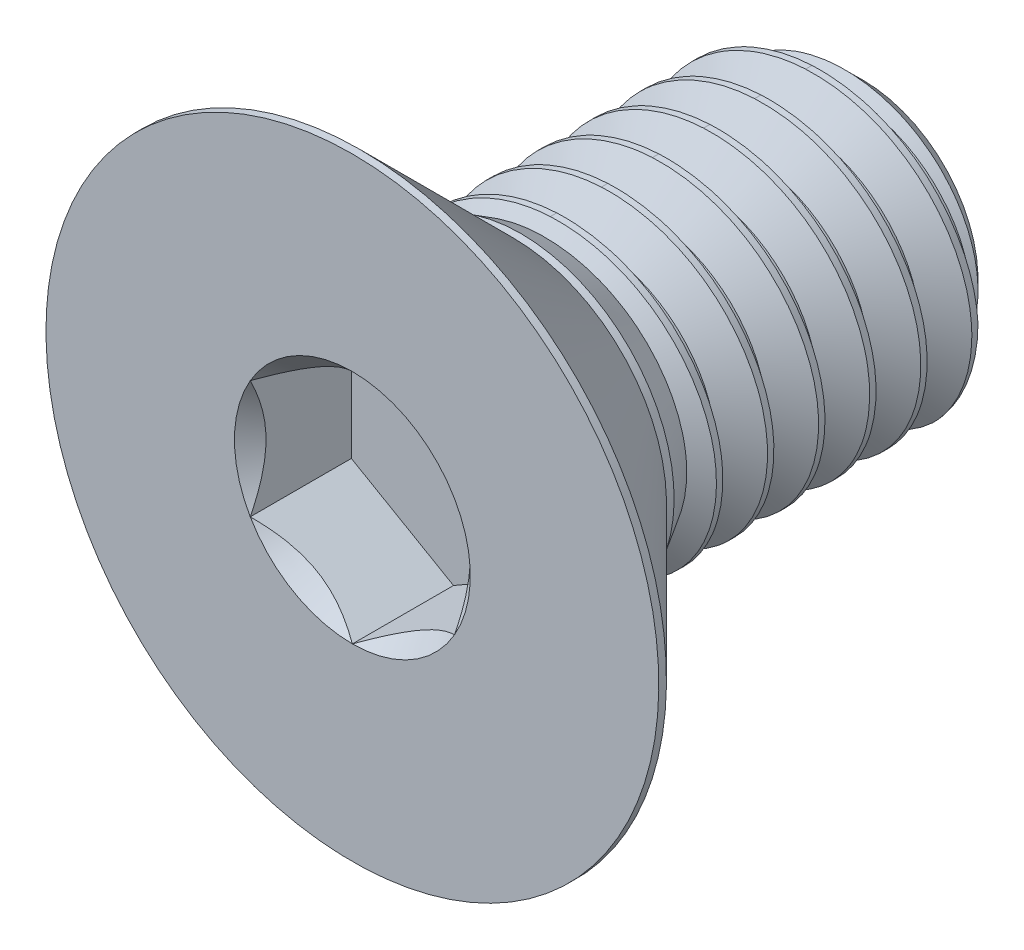
from build123d import *

# Parameters (mm, degrees)
CUT_EXTRUDE2_DEPTH     = 1.98
SKETCH6_R              = 2.309401077
CUT_EXTRUDE3_DEPTH     = 1.98
CUT_EXTRUDE3_DRAFT     = -45
CUT_SWEEP1_PITCH       = 1
CUT_SWEEP1_HEIGHT      = 7.7
CUT_SWEEP1_RADIUS      = 3
CUT_SWEEP1_START_ANGLE = 90


with BuildPart() as part:
    # Sketch7 → Revolve2 (revolve)
    with BuildSketch(Plane(origin=(0, 0, 0), x_dir=(0, 0, -1), z_dir=(1, 0, 0))):
        Polygon((-3.3, 0), (-3.3, 6), (-3.15, 6), (-0.15, 3), (5.95, 3), (6.7, 2.25), (6.7, 0), align=None)
    revolve(axis=Axis((0, 0, -6.7), (0, 0, 1)))

    # Sketch5 → Cut-Extrude2 (cut)
    with BuildSketch(Plane.XY.offset(3.3)):
        Polygon((2, -1.154700538), (2, 1.154700538), (0, 2.309401077), (-2, 1.154700538), (-2, -1.154700538), (0, -2.309401077), align=None)
    extrude(amount=-CUT_EXTRUDE2_DEPTH, mode=Mode.SUBTRACT)


with BuildPart() as cut_extrude3_tool:
    # Sketch6 → Cut-Extrude3 (with draft: the straight prism first)
    with BuildSketch(Plane.XY.offset(3.3)):
        Circle(SKETCH6_R)
    extrude(amount=-CUT_EXTRUDE3_DEPTH)
    # Cut-Extrude3: the draft: its side faces are tilted about the plane it starts from
    cut_extrude3_sides = [cut_extrude3_tool.faces().sort_by_distance(p)[0] for p in [
        (-2.309401077, 0, 2.31),
    ]]
    draft(cut_extrude3_sides, Plane.XY.offset(3.3), CUT_EXTRUDE3_DRAFT)


with BuildPart() as part_1:
    add(part.part)

    # Cut-Extrude3: cut by cut_extrude3_tool
    add(cut_extrude3_tool.part, mode=Mode.SUBTRACT)


with BuildPart() as body_2:
    # Split1: the piece on the far side of the plane
    add(part_1.part)
    split(bisect_by=Plane.XY, keep=Keep.BOTTOM)

    # Cut-Sweep1: sweep along a helix
    with BuildLine() as cut_sweep1_path:
        add(Helix(CUT_SWEEP1_PITCH, CUT_SWEEP1_HEIGHT, CUT_SWEEP1_RADIUS, center=(0, 0, -6.7), direction=(0, 0, 1), mode=Mode.PRIVATE).rotate(Axis((0, 0, -6.7), (0, 0, 1)), CUT_SWEEP1_START_ANGLE))
    # Sketch8 → Cut-Sweep1 (sweep, cut)
    with BuildSketch(Plane(origin=(0, 0, 0), x_dir=(0, 0, -1), z_dir=(1, 0, 0))):
        Polygon((6.66875, 3.054126588), (7.60625, 3.054126588), (7.2, 2.350480947), (7.075, 2.350480947), align=None)
    sweep(path=cut_sweep1_path.line, is_frenet=True, mode=Mode.SUBTRACT)


with BuildPart() as part_2:
    add(part_1.part)

    # Split1
    split(bisect_by=Plane.XY, keep=Keep.TOP)

    add(body_2.part)  # Boss-Extrude1 merges body 2
    # Boss-Extrude1 cone 1 section (through the dimple's axis) → Boss-Extrude1 (revolve)
    with BuildSketch(Plane(origin=(0, 0, 0), x_dir=(0, -1, 0), z_dir=(1, 0, 0))):
        Polygon((0, 0), (3, 0), (0, 5.012634734), align=None)
    revolve(axis=Axis((0, 0, 0), (0, 0, -1)))


solid = part_2.part
